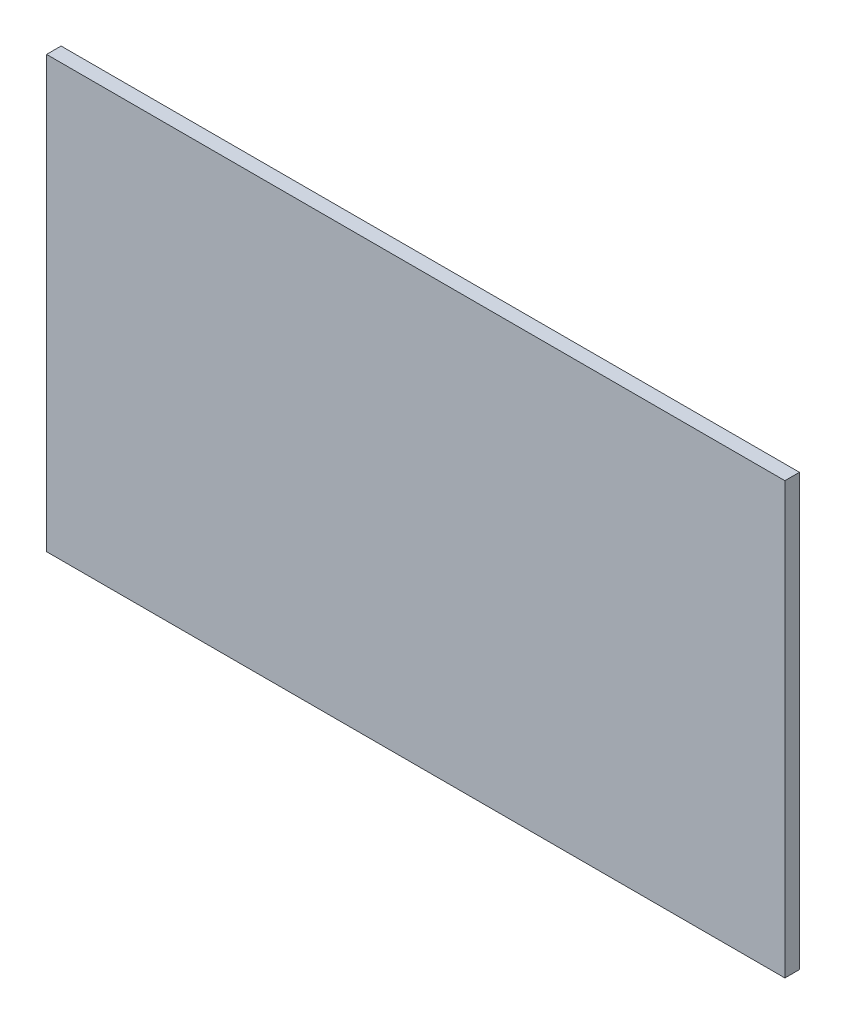
from build123d import *

# Parameters (mm, degrees)
SKETCH1_W           = 152.4
SKETCH1_H           = 88.9
BOSS_EXTRUDE1_DEPTH = 2.9972


with BuildPart() as part:
    # Sketch1 → Boss-Extrude1 (new body)
    with BuildSketch(Plane.XY):
        with Locations((76.2, -44.45)):
            Rectangle(SKETCH1_W, SKETCH1_H)
    extrude(amount=BOSS_EXTRUDE1_DEPTH)


solid = part.part
